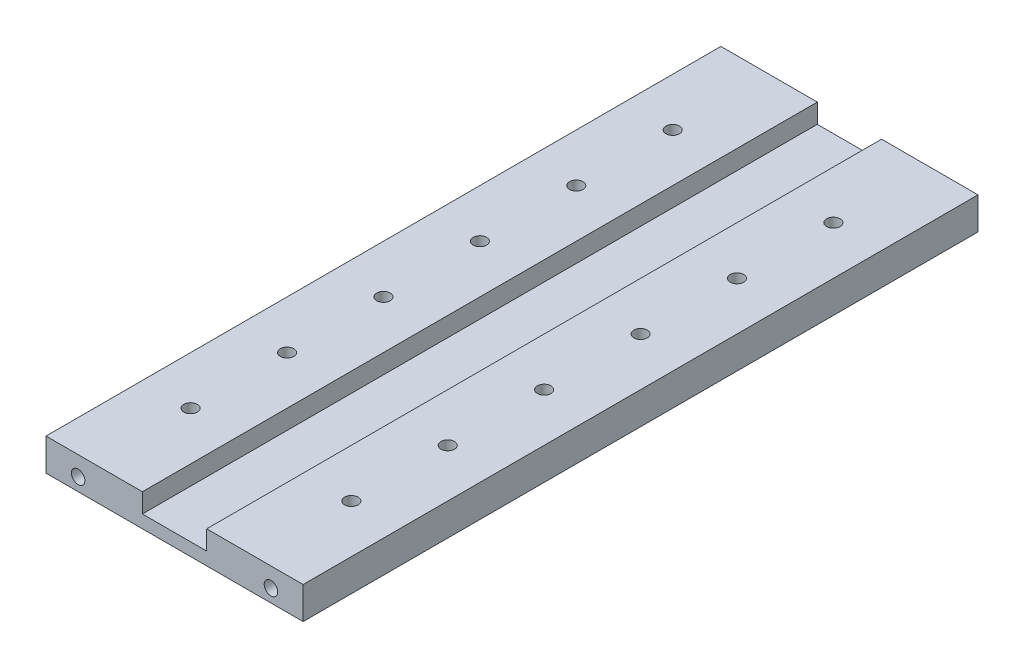
from build123d import *

# Parameters (mm, degrees)
AUFSATZ_LINEAR_AUSTRAGEN1_DEPTH = 105
M5_GEWINDEBOHRUNG1_D            = 4.2
M5_GEWINDEBOHRUNG1_DEPTH        = 14
M5_GEWINDEBOHRUNG1_TIP          = 1.2618073
M5_GEWINDEBOHRUNG2_D            = 4.2
M5_GEWINDEBOHRUNG2_DEPTH        = 14
M5_GEWINDEBOHRUNG2_TIP          = 1.2618073
M5_GEWINDEBOHRUNG3_D            = 4.2


with BuildPart() as part:
    # Skizze1 → Aufsatz-Linear austragen1 (new body, symmetric)
    with BuildSketch(Plane.XY):
        Polygon((-40, 0), (40, 0), (40, 10), (10, 10), (10, 4), (-10, 4), (-10, 10), (-40, 10), align=None)
    extrude(amount=AUFSATZ_LINEAR_AUSTRAGEN1_DEPTH, both=True)

    # M5 Gewindebohrung1
    with Locations(Plane.XY.offset(105)):
        with Locations((-30, 4), (30, 4)):
            Hole(M5_GEWINDEBOHRUNG1_D / 2, depth=M5_GEWINDEBOHRUNG1_DEPTH)
            with Locations((0, 0, -(M5_GEWINDEBOHRUNG1_DEPTH + M5_GEWINDEBOHRUNG1_TIP / 2))):  # 118° drill point
                Cone(0, M5_GEWINDEBOHRUNG1_D / 2, M5_GEWINDEBOHRUNG1_TIP, mode=Mode.SUBTRACT)

    # M5 Gewindebohrung2
    with Locations(Plane(origin=(0, 0, -105), x_dir=(-1, 0, 0), z_dir=(0, 0, -1))):
        with Locations((-25, 5), (25, 5)):
            Hole(M5_GEWINDEBOHRUNG2_D / 2, depth=M5_GEWINDEBOHRUNG2_DEPTH)
            with Locations((0, 0, -(M5_GEWINDEBOHRUNG2_DEPTH + M5_GEWINDEBOHRUNG2_TIP / 2))):  # 118° drill point
                Cone(0, M5_GEWINDEBOHRUNG2_D / 2, M5_GEWINDEBOHRUNG2_TIP, mode=Mode.SUBTRACT)

    # M5 Gewindebohrung3 (through all)
    with Locations(Plane(origin=(0, 10, 0), x_dir=(1, 0, 0), z_dir=(0, 1, 0))):
        with Locations((25, -75), (-25, -75), (-25, -45), (-25, -15), (-25, 15), (-25, 45), (-25, 75), (25, 75), (25, 45), (25, 15), (25, -15), (25, -45)):
            Hole(M5_GEWINDEBOHRUNG3_D / 2)


solid = part.part
